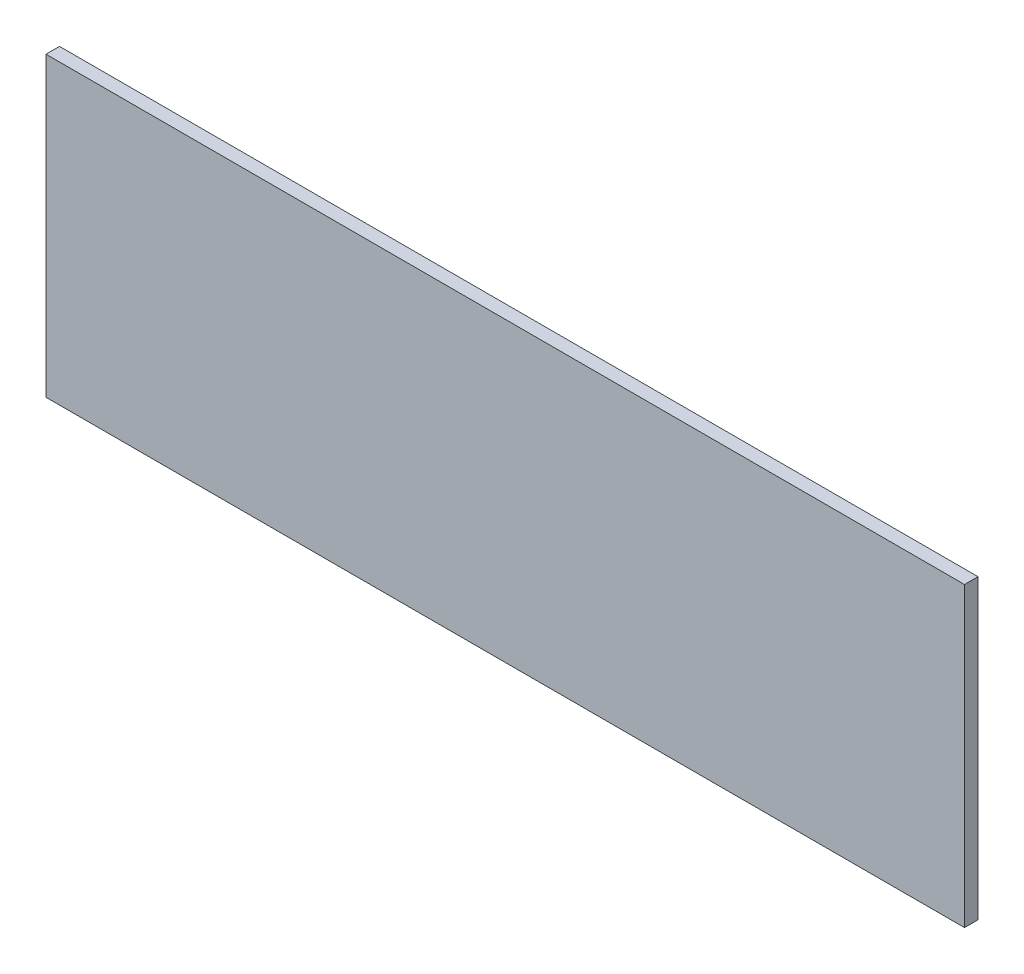
from build123d import *

# Parameters (mm, degrees)
SKETCH1_W           = 431.8
SKETCH1_H           = 139.7
BOSS_EXTRUDE1_DEPTH = 6.35


with BuildPart() as part:
    # Sketch1 → Boss-Extrude1 (new body)
    with BuildSketch(Plane.XY):
        with Locations((215.9, 69.85)):
            Rectangle(SKETCH1_W, SKETCH1_H)
    extrude(amount=BOSS_EXTRUDE1_DEPTH)


solid = part.part
